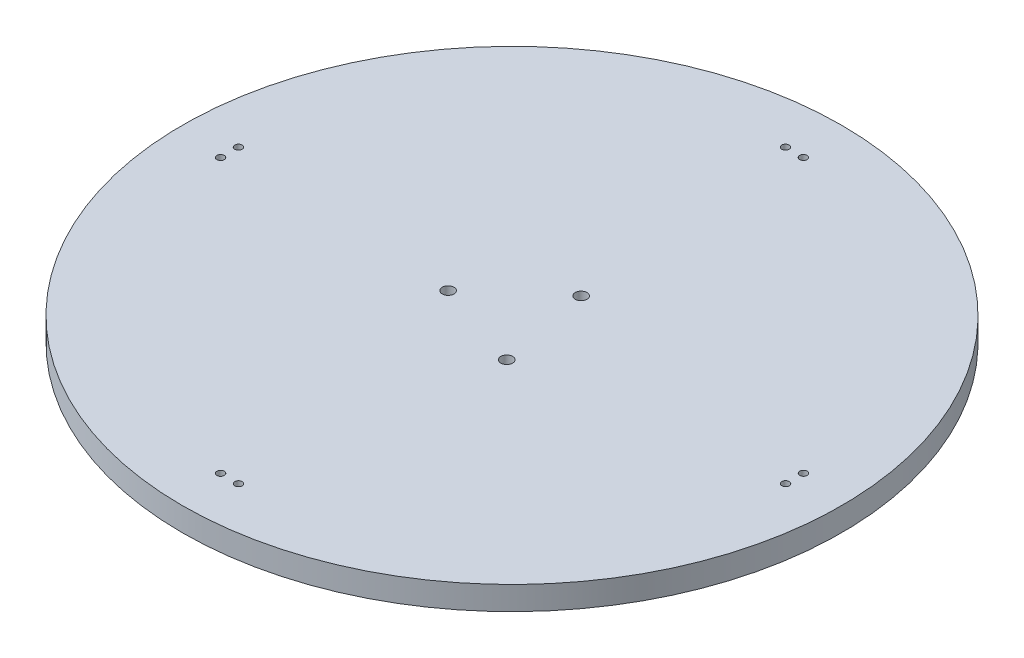
from build123d import *

# Parameters (mm, degrees)
SKETCH1_R           = 88.9
BOSS_EXTRUDE1_DEPTH = 6.35
CUT_EXTRUDE1_REACH  = 8.35
SKETCH2_R           = 1
CUT_EXTRUDE2_REACH  = 8.35
SKETCH4_R           = 1.5875


with BuildPart() as part:
    # Sketch1 → Boss-Extrude1 (new body)
    with BuildSketch(Plane(origin=(0, 0, 0), x_dir=(1, 0, 0), z_dir=(0, 1, 0))):
        Circle(SKETCH1_R)
    extrude(amount=BOSS_EXTRUDE1_DEPTH)

    # Sketch2 → Cut-Extrude1 (cut, up to next)
    with BuildSketch(Plane.XZ, mode=Mode.PRIVATE) as cut_extrude1_sk1:
        with Locations((2.411677935, -76.2)):
            Circle(SKETCH2_R)
    cut_extrude1_tool1 = extrude(cut_extrude1_sk1.sketch, amount=-CUT_EXTRUDE1_REACH, mode=Mode.PRIVATE) & part.part
    add(cut_extrude1_tool1.solids().sort_by_distance((2.411678, 0, -76.2))[0], mode=Mode.SUBTRACT)
    # Sketch2 → Cut-Extrude1 (cut, up to next)
    with BuildSketch(Plane.XZ, mode=Mode.PRIVATE) as cut_extrude1_sk2:
        with Locations((-2.425285476, -76.2)):
            Circle(SKETCH2_R)
    cut_extrude1_tool2 = extrude(cut_extrude1_sk2.sketch, amount=-CUT_EXTRUDE1_REACH, mode=Mode.PRIVATE) & part.part
    add(cut_extrude1_tool2.solids().sort_by_distance((-2.425285, 0, -76.2))[0], mode=Mode.SUBTRACT)
    # Sketch2 → Cut-Extrude1 (cut, up to next)
    with BuildSketch(Plane.XZ, mode=Mode.PRIVATE) as cut_extrude1_sk3:
        with Locations((-76.2, -2.411677935)):
            Circle(SKETCH2_R)
    cut_extrude1_tool3 = extrude(cut_extrude1_sk3.sketch, amount=-CUT_EXTRUDE1_REACH, mode=Mode.PRIVATE) & part.part
    add(cut_extrude1_tool3.solids().sort_by_distance((-76.2, 0, -2.411678))[0], mode=Mode.SUBTRACT)
    # Sketch2 → Cut-Extrude1 (cut, up to next)
    with BuildSketch(Plane.XZ, mode=Mode.PRIVATE) as cut_extrude1_sk4:
        with Locations((-76.2, 2.425285476)):
            Circle(SKETCH2_R)
    cut_extrude1_tool4 = extrude(cut_extrude1_sk4.sketch, amount=-CUT_EXTRUDE1_REACH, mode=Mode.PRIVATE) & part.part
    add(cut_extrude1_tool4.solids().sort_by_distance((-76.2, 0, 2.425285))[0], mode=Mode.SUBTRACT)
    # Sketch2 → Cut-Extrude1 (cut, up to next)
    with BuildSketch(Plane.XZ, mode=Mode.PRIVATE) as cut_extrude1_sk5:
        with Locations((-2.411677935, 76.2)):
            Circle(SKETCH2_R)
    cut_extrude1_tool5 = extrude(cut_extrude1_sk5.sketch, amount=-CUT_EXTRUDE1_REACH, mode=Mode.PRIVATE) & part.part
    add(cut_extrude1_tool5.solids().sort_by_distance((-2.411678, 0, 76.2))[0], mode=Mode.SUBTRACT)
    # Sketch2 → Cut-Extrude1 (cut, up to next)
    with BuildSketch(Plane.XZ, mode=Mode.PRIVATE) as cut_extrude1_sk6:
        with Locations((2.425285476, 76.2)):
            Circle(SKETCH2_R)
    cut_extrude1_tool6 = extrude(cut_extrude1_sk6.sketch, amount=-CUT_EXTRUDE1_REACH, mode=Mode.PRIVATE) & part.part
    add(cut_extrude1_tool6.solids().sort_by_distance((2.425285, 0, 76.2))[0], mode=Mode.SUBTRACT)
    # Sketch2 → Cut-Extrude1 (cut, up to next)
    with BuildSketch(Plane.XZ, mode=Mode.PRIVATE) as cut_extrude1_sk7:
        with Locations((76.2, 2.411677935)):
            Circle(SKETCH2_R)
    cut_extrude1_tool7 = extrude(cut_extrude1_sk7.sketch, amount=-CUT_EXTRUDE1_REACH, mode=Mode.PRIVATE) & part.part
    add(cut_extrude1_tool7.solids().sort_by_distance((76.2, 0, 2.411678))[0], mode=Mode.SUBTRACT)
    # Sketch2 → Cut-Extrude1 (cut, up to next)
    with BuildSketch(Plane.XZ, mode=Mode.PRIVATE) as cut_extrude1_sk8:
        with Locations((76.2, -2.425285476)):
            Circle(SKETCH2_R)
    cut_extrude1_tool8 = extrude(cut_extrude1_sk8.sketch, amount=-CUT_EXTRUDE1_REACH, mode=Mode.PRIVATE) & part.part
    add(cut_extrude1_tool8.solids().sort_by_distance((76.2, 0, -2.425285))[0], mode=Mode.SUBTRACT)

    # Sketch4 → Cut-Extrude2 (cut, up to next)
    with BuildSketch(Plane.XZ, mode=Mode.PRIVATE) as cut_extrude2_sk1:
        with Locations((4.766839139, -13.885779707)):
            Circle(SKETCH4_R)
    cut_extrude2_tool1 = extrude(cut_extrude2_sk1.sketch, amount=-CUT_EXTRUDE2_REACH, mode=Mode.PRIVATE) & part.part
    add(cut_extrude2_tool1.solids().sort_by_distance((4.766839, 0, -13.88578))[0], mode=Mode.SUBTRACT)
    # Sketch4 → Cut-Extrude2 (cut, up to next)
    with BuildSketch(Plane.XZ, mode=Mode.PRIVATE) as cut_extrude2_sk2:
        with Locations((-14.408857547, 2.814686063)):
            Circle(SKETCH4_R)
    cut_extrude2_tool2 = extrude(cut_extrude2_sk2.sketch, amount=-CUT_EXTRUDE2_REACH, mode=Mode.PRIVATE) & part.part
    add(cut_extrude2_tool2.solids().sort_by_distance((-14.408858, 0, 2.814686))[0], mode=Mode.SUBTRACT)
    # Sketch4 → Cut-Extrude2 (cut, up to next)
    with BuildSketch(Plane.XZ, mode=Mode.PRIVATE) as cut_extrude2_sk3:
        with Locations((9.642018407, 11.071093644)):
            Circle(SKETCH4_R)
    cut_extrude2_tool3 = extrude(cut_extrude2_sk3.sketch, amount=-CUT_EXTRUDE2_REACH, mode=Mode.PRIVATE) & part.part
    add(cut_extrude2_tool3.solids().sort_by_distance((9.642018, 0, 11.071094))[0], mode=Mode.SUBTRACT)


solid = part.part
